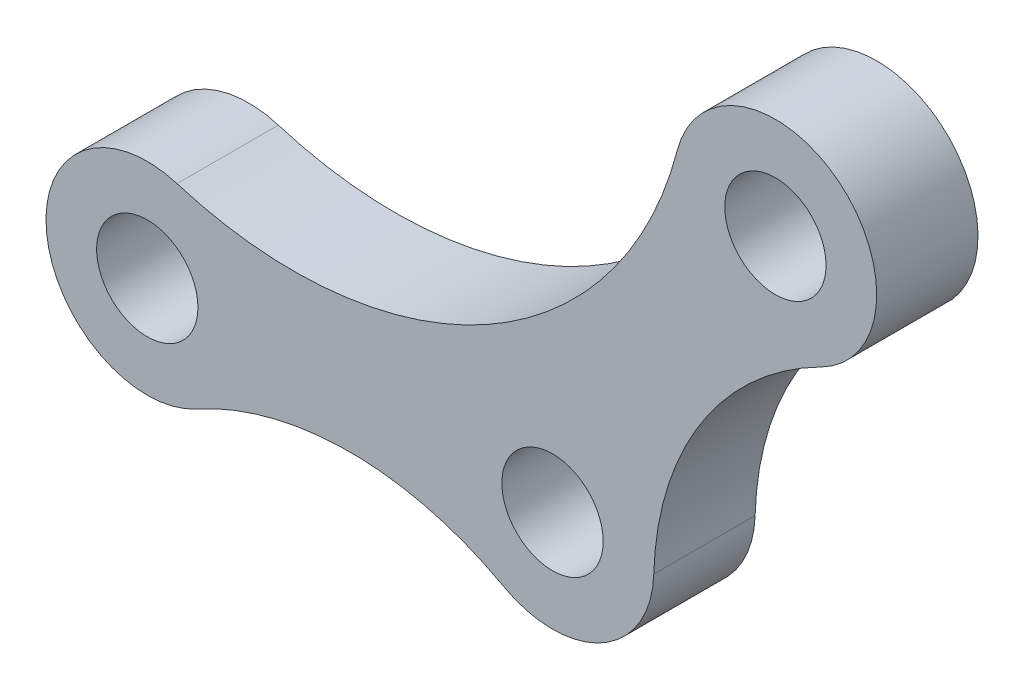
from build123d import *

# Parameters (mm, degrees)
SKETCH_1_R          = 2.5
EXTRUDE_1_DEPTH     = 2.5
SKETCH_2_OUTSIDE_W  = 52.902
SKETCH_2_OUTSIDE_H  = 39.201
CUT_EXTRUDE_1_DEPTH = 5


with BuildPart() as part:
    # 草圖1 → 填料-伸長1 (new body, symmetric)
    with BuildSketch(Plane.XY):
        with BuildLine():
            Line((28.563543114, 21.665041075), (-2.436456886, 4.366197183))
            ThreePointArc((-2.436456886, 4.366197183), (-4.838955771, -1.258772037), (0, -5))
            Line((0, -5), (20, -5))
            ThreePointArc((20, -5), (22.406799312, -4.382615323), (24.219230218, -2.682926829))
            Line((24.219230218, -2.682926829), (35.219230218, 14.615917063))
            ThreePointArc((35.219230218, 14.615917063), (34.635534008, 20.7314657), (28.563543114, 21.665041075))
        make_face()
        Circle(SKETCH_1_R, mode=Mode.SUBTRACT)
        with Locations((20, 0)):
            Circle(SKETCH_1_R, mode=Mode.SUBTRACT)
        with Locations((31, 17.298843892)):
            Circle(SKETCH_1_R, mode=Mode.SUBTRACT)
    extrude(amount=EXTRUDE_1_DEPTH, both=True)

    # 草圖2 outside → 除料-伸長1 (cut)
    with BuildSketch(Plane.XY.offset(2.5)):
        with Locations((15.5, 8.6495)):
            Rectangle(SKETCH_2_OUTSIDE_W, SKETCH_2_OUTSIDE_H)
        with BuildLine():
            ThreePointArc((1.466809122, 4.780007427), (-4.973314603, -0.515889385), (2.416696414, -4.377165572))
            ThreePointArc((2.416696414, -4.377165572), (10, -2.422785813), (17.583303586, -4.377165572))
            ThreePointArc((17.583303586, -4.377165572), (22.479295807, -4.342014774), (24.997943304, -0.143397121))
            ThreePointArc((24.997943304, -0.143397121), (27.336128289, 7.481863506), (33.249748223, 12.833574255))
            ThreePointArc((33.249748223, 12.833574255), (34.142354704, 21.188009216), (26.161789901, 18.560478956))
            ThreePointArc((26.161789901, 18.560478956), (16.754800429, 6.400785359), (1.466809122, 4.780007427))
        make_face(mode=Mode.SUBTRACT)
    extrude(amount=-CUT_EXTRUDE_1_DEPTH, mode=Mode.SUBTRACT)


solid = part.part
